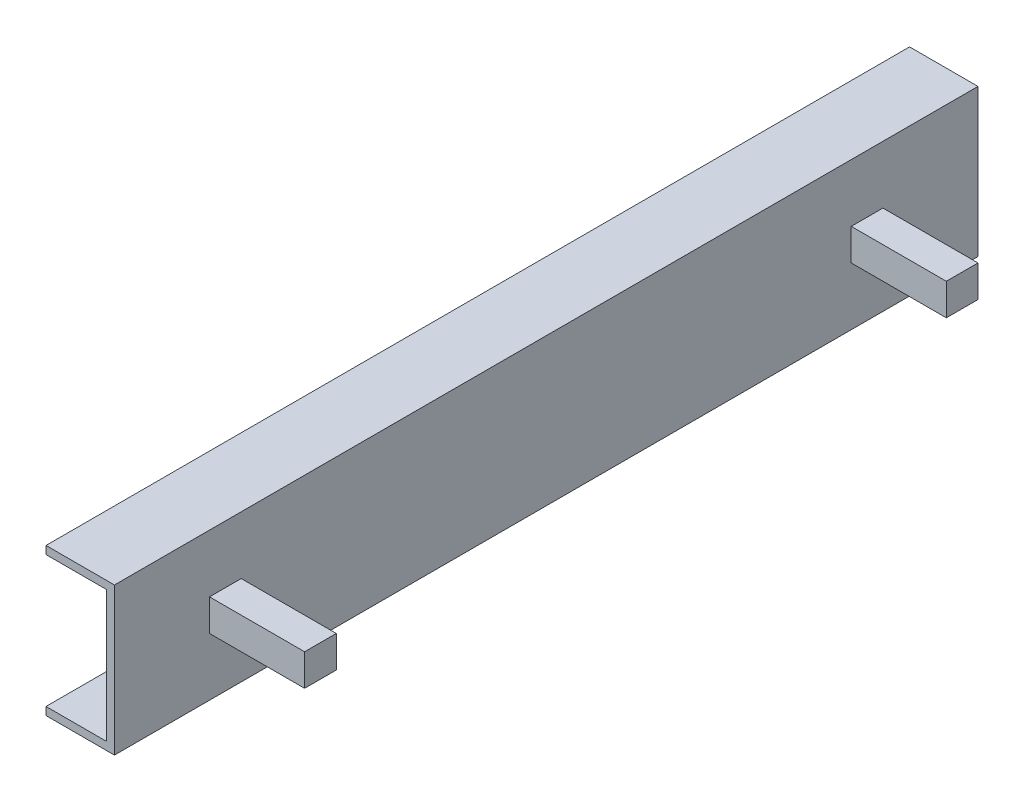
from build123d import *

# Parameters (mm, degrees)
BOSS_EXTRUDE1_DEPTH = 346.075
SKETCH2_W           = 25.4
SKETCH2_H           = 25.4
BOSS_EXTRUDE2_DEPTH = 76.2


with BuildPart() as part:
    # Sketch1 → Boss-Extrude1 (new body, symmetric)
    with BuildSketch(Plane.XY):
        Polygon((0, 0), (0, 59.055), (-54.864, 59.055), (-54.864, 52.705), (-6.35, 52.705), (-6.35, 0), align=None)
    boss_extrude1 = extrude(amount=BOSS_EXTRUDE1_DEPTH, both=True)

    # Mirror1: Boss-Extrude1 across plane
    add(boss_extrude1.mirror(Plane(origin=(-6.35, 0, 346.075), x_dir=(0, 0, 1), z_dir=(0, 1, 0))))

    # Sketch2 → Boss-Extrude2 (add)
    with BuildSketch(Plane(origin=(0, 0, 0), x_dir=(0, 0, -1), z_dir=(1, 0, 0))):
        with Locations((-257.175, 0)):
            Rectangle(SKETCH2_W, SKETCH2_H)
    boss_extrude2 = extrude(amount=BOSS_EXTRUDE2_DEPTH)

    # Mirror2: Boss-Extrude2 across plane
    add(boss_extrude2.mirror(Plane.XY))


solid = part.part
